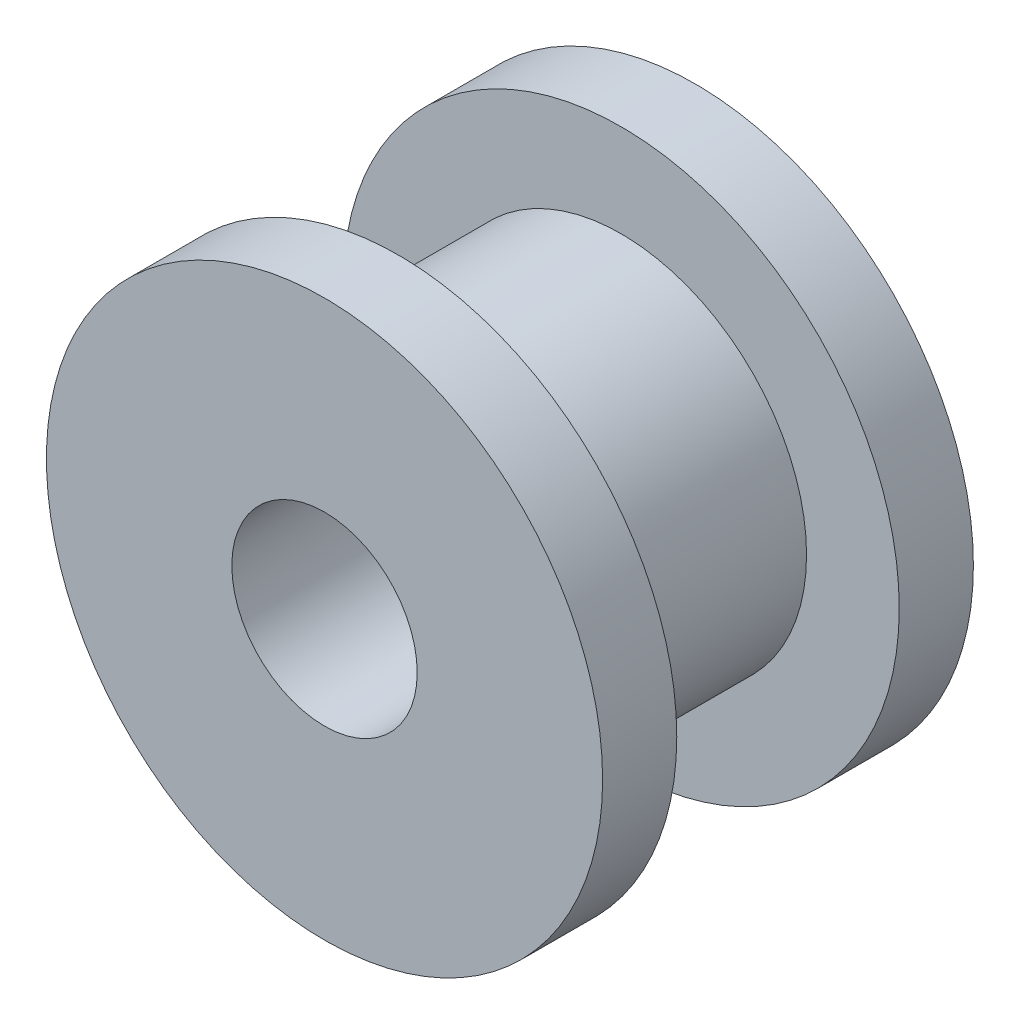
from build123d import *

# Parameters (mm, degrees)
SKETCH1_R           = 9.525
BOSS_EXTRUDE1_DEPTH = 2.54
SKETCH2_R           = 6.35
BOSS_EXTRUDE2_DEPTH = 7.62
CUT_EXTRUDE1_REACH  = 14.7
SKETCH4_R           = 3.175


with BuildPart() as part:
    # Sketch1 → Boss-Extrude1 (new body)
    with BuildSketch(Plane.XY):
        Circle(SKETCH1_R)
    boss_extrude1 = extrude(amount=BOSS_EXTRUDE1_DEPTH)

    # Sketch2 → Boss-Extrude2 (add)
    with BuildSketch(Plane.XY.offset(2.54)):
        Circle(SKETCH2_R)
    extrude(amount=BOSS_EXTRUDE2_DEPTH)

    # Mirror1: Boss-Extrude1 across plane
    add(boss_extrude1.mirror(Plane.XY.offset(6.35)))

    # Sketch4 → Cut-Extrude1 (cut, up to next)
    with BuildSketch(Plane.XY.offset(12.7), mode=Mode.PRIVATE) as cut_extrude1_sk1:
        Circle(SKETCH4_R)
    cut_extrude1_tool1 = extrude(cut_extrude1_sk1.sketch, amount=-CUT_EXTRUDE1_REACH, mode=Mode.PRIVATE) & part.part
    add(cut_extrude1_tool1.solids().sort_by_distance((0, 0, 12.7))[0], mode=Mode.SUBTRACT)


solid = part.part
